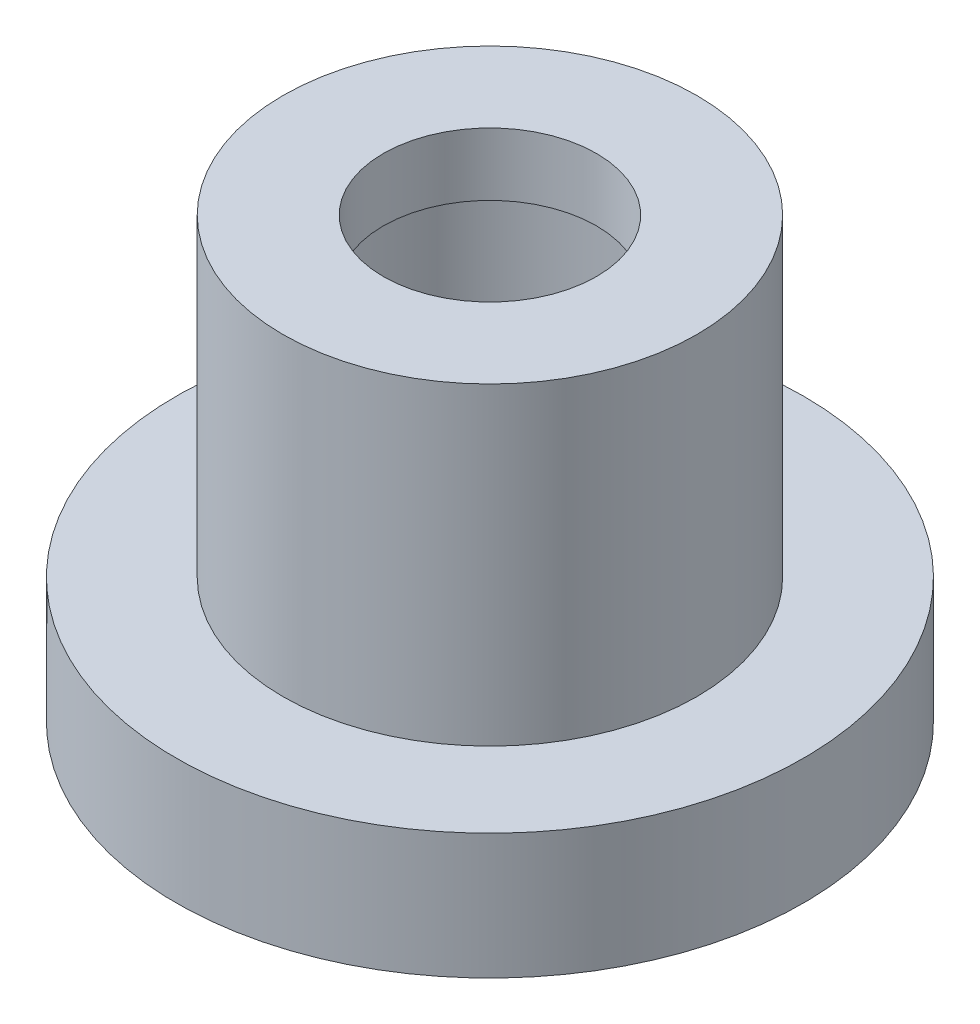
from build123d import *

# Parameters (mm, degrees)
SKETCH3_R           = 3.3
SKETCH3_R_2         = 2.3
BOSS_EXTRUDE3_DEPTH = 7
SKETCH4_R           = 5
SKETCH4_R_2         = 3.3
BOSS_EXTRUDE4_DEPTH = 2
SKETCH5_R           = 2.3
SKETCH5_R_2         = 1.7
BOSS_EXTRUDE5_DEPTH = 1


with BuildPart() as part:
    # Sketch3 → Boss-Extrude3 (new body)
    with BuildSketch(Plane(origin=(0, 0, 0), x_dir=(1, 0, 0), z_dir=(0, 1, 0))):
        Circle(SKETCH3_R)
        Circle(SKETCH3_R_2, mode=Mode.SUBTRACT)
    extrude(amount=BOSS_EXTRUDE3_DEPTH)

    # Sketch4 → Boss-Extrude4 (add)
    with BuildSketch(Plane.XZ):
        Circle(SKETCH4_R)
        Circle(SKETCH4_R_2, mode=Mode.SUBTRACT)
    extrude(amount=-BOSS_EXTRUDE4_DEPTH)

    # Sketch5 → Boss-Extrude5 (add)
    with BuildSketch(Plane(origin=(0, 7, 0), x_dir=(1, 0, 0), z_dir=(0, 1, 0))):
        Circle(SKETCH5_R)
        Circle(SKETCH5_R_2, mode=Mode.SUBTRACT)
    extrude(amount=-BOSS_EXTRUDE5_DEPTH)


solid = part.part
